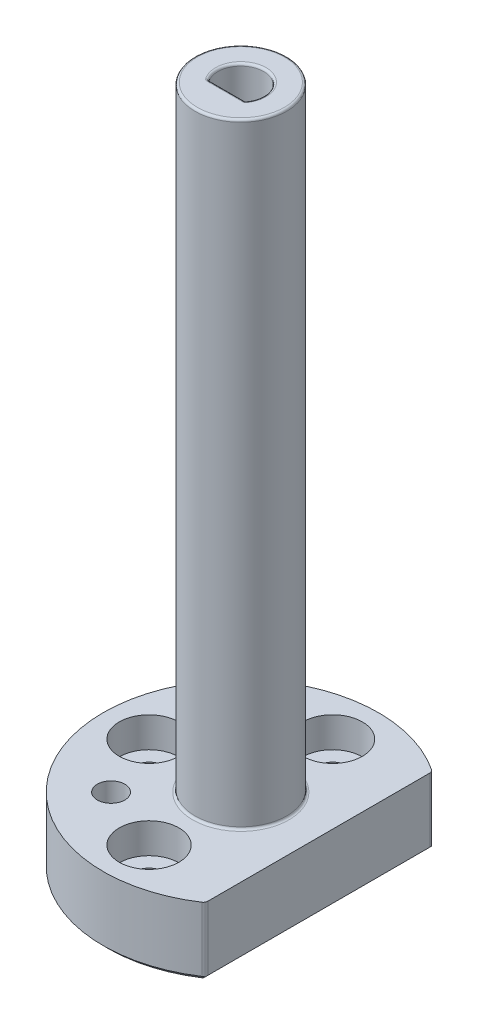
from build123d import *

# Parameters (mm, degrees)
BOSS_EXTRUDE1_DEPTH = 15
SKETCH2_R           = 10
BOSS_EXTRUDE2_DEPTH = 134
SKETCH4_R           = 7.25
CUT_EXTRUDE1_DEPTH  = 57
CUT_EXTRUDE2_DEPTH  = 93
SKETCH7_R           = 6.5
CUT_EXTRUDE3_DEPTH  = 6.6
SKETCH8_R           = 3.2
CUT_EXTRUDE4_DEPTH  = 9.4
FILLET1_R           = 0.25
CHAMFER1_SIZE       = 1
FILLET2_R           = 0.5
FILLET3_R           = 0.5
FILLET4_R           = 0.5
SKETCH9_R           = 3
CUT_EXTRUDE5_DEPTH  = 16
FILLET5_R           = 1


with BuildPart() as part:
    # Sketch1 → Boss-Extrude1 (new body)
    with BuildSketch(Plane(origin=(0, 0, 0), x_dir=(1, 0, 0), z_dir=(0, 1, 0))):
        with BuildLine():
            Line((17, -24.718414189), (17, 24.718414189))
            ThreePointArc((17, 24.718414189), (-30, 0), (17, -24.718414189))
        make_face()
    extrude(amount=BOSS_EXTRUDE1_DEPTH)

    # Sketch2 → Boss-Extrude2 (add)
    with BuildSketch(Plane(origin=(0, 15, 0), x_dir=(1, 0, 0), z_dir=(0, 1, 0))):
        Circle(SKETCH2_R)
    extrude(amount=BOSS_EXTRUDE2_DEPTH)

    # Sketch4 → Cut-Extrude1 (cut)
    with BuildSketch(Plane.XZ):
        Circle(SKETCH4_R)
    extrude(amount=-CUT_EXTRUDE1_DEPTH, mode=Mode.SUBTRACT)

    # Sketch5 → Cut-Extrude2 (cut, through all)
    with BuildSketch(Plane.XZ.offset(-57)):
        with BuildLine():
            Line((-4, 3), (4, 3))
            ThreePointArc((4, 3), (0, -5), (-4, 3))
        make_face()
    extrude(amount=-CUT_EXTRUDE2_DEPTH, mode=Mode.SUBTRACT)

    # Sketch7 → Cut-Extrude3 (cut)
    with BuildSketch(Plane(origin=(0, 15, 0), x_dir=(1, 0, 0), z_dir=(0, 1, 0))):
        with Locations((0, -20)):
            Circle(SKETCH7_R)
        with Locations((-20, 0)):
            Circle(SKETCH7_R)
        with Locations((0, 20)):
            Circle(SKETCH7_R)
    extrude(amount=-CUT_EXTRUDE3_DEPTH, mode=Mode.SUBTRACT)

    # Sketch8 → Cut-Extrude4 (cut, through all)
    with BuildSketch(Plane(origin=(0, 8.4, 0), x_dir=(1, 0, 0), z_dir=(0, 1, 0))):
        with Locations((0, -20)):
            Circle(SKETCH8_R)
        with Locations((-20, 0)):
            Circle(SKETCH8_R)
        with Locations((0, 20)):
            Circle(SKETCH8_R)
    extrude(amount=-CUT_EXTRUDE4_DEPTH, mode=Mode.SUBTRACT)

    # Fillet1
    fillet1_edges = [part.edges().sort_by_distance(p)[0] for p in [
        (4, 103, 3),
        (-4, 103, 3),
    ]]
    fillet(fillet1_edges, radius=FILLET1_R)

    # Chamfer1
    chamfer1_edges = [part.edges().sort_by_distance(p)[0] for p in [
        (17, 0, 0),
        (-30, 0, 0),
    ]]
    chamfer(chamfer1_edges, length=CHAMFER1_SIZE)

    # Fillet2
    fillet2_edges = [part.edges().sort_by_distance(p)[0] for p in [
        (-10, 149, 0),
    ]]
    fillet(fillet2_edges, radius=FILLET2_R)

    # Fillet3
    fillet3_edges = [part.edges().sort_by_distance(p)[0] for p in [
        (0, 149, 3),
        (0, 149, -5),
        (3.987691213, 149, 2.972130829),
        (-3.987691213, 149, 2.972130829),
    ]]
    fillet(fillet3_edges, radius=FILLET3_R)

    # Fillet4
    fillet4_edges = [part.edges().sort_by_distance(p)[0] for p in [
        (-10, 15, 0),
    ]]
    fillet(fillet4_edges, radius=FILLET4_R)

    # Sketch9 → Cut-Extrude5 (cut, through all)
    with BuildSketch(Plane(origin=(0, 15, 0), x_dir=(1, 0, 0), z_dir=(0, 1, 0))):
        with Locations((-14.142135624, -14.142135624)):
            Circle(SKETCH9_R)
    extrude(amount=-CUT_EXTRUDE5_DEPTH, mode=Mode.SUBTRACT)

    # Fillet5
    fillet5_edges = [part.edges().sort_by_distance(p)[0] for p in [
        (17, 8, -24.718414189),
        (17, 8, 24.718414189),
    ]]
    fillet(fillet5_edges, radius=FILLET5_R)


solid = part.part
